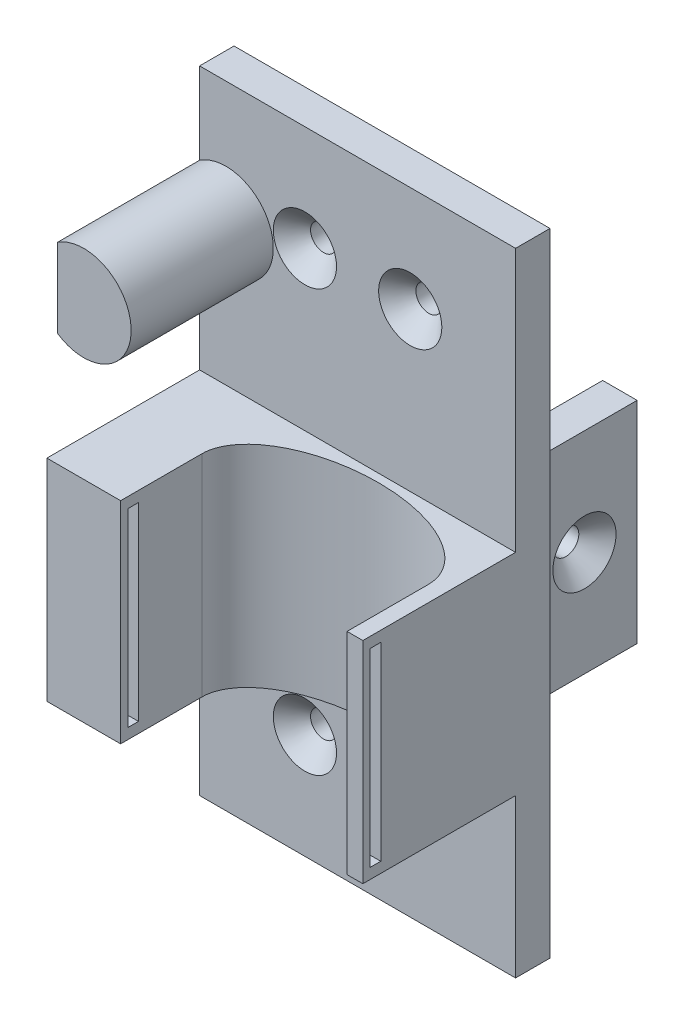
from build123d import *

# Parameters (mm, degrees)
BOSS_EXTRUDE1_DEPTH                             = 6.54
BOSS_EXTRUDE4_DEPTH                             = 27.000000000000004
CSK_FOR_M3_FLAT_HEAD_MACHINE_SCREW2_D           = 4.93
CSK_FOR_M3_FLAT_HEAD_MACHINE_SCREW2_CSINK_D     = 12
CSK_FOR_M3_FLAT_HEAD_MACHINE_SCREW2_CSINK_ANGLE = 90
BOSS_EXTRUDE5_DEPTH                             = 20
BOSS_EXTRUDE6_DEPTH                             = 28.999999999999996
CUT_EXTRUDE1_REACH                              = 86.042
SKETCH18_RX                                     = 21.5
SKETCH18_RY                                     = 11.999999999999996
CUT_EXTRUDE2_REACH                              = 89.09
CUT_EXTRUDE3_DEPTH                              = 8.999999999999996
CUT_EXTRUDE4_DEPTH                              = 8.999999999999996
CSK_FOR_M3_FLAT_HEAD_MACHINE_SCREW4_D           = 4.93
CSK_FOR_M3_FLAT_HEAD_MACHINE_SCREW4_DEPTH       = 6.54
CSK_FOR_M3_FLAT_HEAD_MACHINE_SCREW4_CSINK_D     = 12
CSK_FOR_M3_FLAT_HEAD_MACHINE_SCREW4_CSINK_ANGLE = 90
CSK_FOR_M3_FLAT_HEAD_MACHINE_SCREW5_D           = 4.93
CSK_FOR_M3_FLAT_HEAD_MACHINE_SCREW5_CSINK_D     = 12
CSK_FOR_M3_FLAT_HEAD_MACHINE_SCREW5_CSINK_ANGLE = 90


with BuildPart() as part:
    # Sketch1 → Boss-Extrude1 (new body)
    with BuildSketch(Plane.XY):
        Polygon((-30.000000000000004, 59.99999999999999), (29.999999999999996, 59.99999999999999), (30.00000000000001, -60.00000000000001), (-29.99999999999999, -60.00000000000001), align=None)
    extrude(amount=BOSS_EXTRUDE1_DEPTH)

    # Sketch7 → Boss-Extrude4 (add)
    with BuildSketch(Plane.XY.offset(6.54)):
        with BuildLine():
            Line((-30.000000000000004, 44.48331477354787), (-30.000000000000004, 29.516685226452115))
            ThreePointArc((-30.000000000000004, 29.516685226452115), (-15.999999999999986, 36.99999999999999), (-30.000000000000004, 44.48331477354787))
        make_face()
    extrude(amount=BOSS_EXTRUDE4_DEPTH)

    # CSK for M3 Flat Head Machine Screw2 (through all)
    with Locations(Plane(origin=(-10, -40, 6.54), x_dir=(1, 0, 0), z_dir=(0, 0, 1))):
        with Locations((0, 0), (20, 0), (0, 80), (20, 80)):
            CounterSinkHole(CSK_FOR_M3_FLAT_HEAD_MACHINE_SCREW2_D / 2, CSK_FOR_M3_FLAT_HEAD_MACHINE_SCREW2_CSINK_D / 2, counter_sink_angle=CSK_FOR_M3_FLAT_HEAD_MACHINE_SCREW2_CSINK_ANGLE)

    # Sketch10 → Boss-Extrude5 (add)
    with BuildSketch(Plane(origin=(0, 0, 0), x_dir=(-1, 0, 0), z_dir=(0, 0, -1))):
        Polygon((20, 20), (26.540000000000003, 20), (26.540000000000006, -20.000000000000007), (20, -20.000000000000007), align=None)
        Polygon((-20, -20), (-20, 19.999999999999993), (-26.540000000000003, 19.999999999999993), (-26.54, -20), align=None)
    extrude(amount=BOSS_EXTRUDE5_DEPTH)

    # Sketch17 → Boss-Extrude6 (add)
    with BuildSketch(Plane.XY.offset(6.54)):
        Polygon((-30, 9.999999999999995), (30.000000000000014, 9.999999999999995), (30.00000000000001, -30.000000000000007), (-29.999999999999996, -30.000000000000007), align=None)
    extrude(amount=BOSS_EXTRUDE6_DEPTH)

    # Sketch18 → Cut-Extrude1 (cut, up to next)
    with BuildSketch(Plane(origin=(0, 9.999999999999995, 0), x_dir=(1, 0, 0), z_dir=(0, 1, 0)), mode=Mode.PRIVATE) as cut_extrude1_sk1:
        with Locations((5.500000000000008, -20.091951128620167)):
            Ellipse(SKETCH18_RX, SKETCH18_RY)
    cut_extrude1_tool1 = extrude(cut_extrude1_sk1.sketch, amount=-CUT_EXTRUDE1_REACH, mode=Mode.PRIVATE) & part.part
    add(cut_extrude1_tool1.solids().sort_by_distance((5.5, 10, 20.091951))[0], mode=Mode.SUBTRACT)

    # Sketch21 → Cut-Extrude2 (cut, up to next)
    with BuildSketch(Plane.XY.offset(35.53999999999999), mode=Mode.PRIVATE) as cut_extrude2_sk1:
        Polygon((-15.99999999999999, 9.999999999999995), (27.00000000000001, 9.999999999999995), (27.00000000000002, -30.000000000000007), (-15.999999999999986, -30.000000000000007), align=None)
    cut_extrude2_tool1 = extrude(cut_extrude2_sk1.sketch, amount=-CUT_EXTRUDE2_REACH, mode=Mode.PRIVATE) & part.part
    add(cut_extrude2_tool1.solids().sort_by_distance((5.5, -10, 35.54))[0], mode=Mode.SUBTRACT)

    # Sketch23 → Cut-Extrude3 (cut)
    with BuildSketch(Plane(origin=(-15.99999999999999, -1.39e-15, 0), x_dir=(0, 0, -1), z_dir=(1, 9e-17, 0))):
        Polygon((-34.139999999999986, 7.9999999999999964), (-32.13999999999999, 7.9999999999999964), (-32.139999999999986, -28.000000000000007), (-34.139999999999986, -28), align=None)
    extrude(amount=-CUT_EXTRUDE3_DEPTH, mode=Mode.SUBTRACT)

    # Sketch24 → Cut-Extrude4 (cut)
    with BuildSketch(Plane.ZY.offset(-27.000000000000014)):
        Polygon((32.13999999999999, 7.9999999999999885), (34.14, 7.9999999999999885), (34.14, -28.00000000000001), (32.14, -28.00000000000001), align=None)
    extrude(amount=-CUT_EXTRUDE4_DEPTH, mode=Mode.SUBTRACT)

    # CSK for M3 Flat Head Machine Screw4
    with Locations(Plane(origin=(-26.54, 0, -10), x_dir=(0, -1, 0), z_dir=(-1, 0, 0))):
        with Locations((0, 0)):
            CounterSinkHole(CSK_FOR_M3_FLAT_HEAD_MACHINE_SCREW4_D / 2, CSK_FOR_M3_FLAT_HEAD_MACHINE_SCREW4_CSINK_D / 2, depth=CSK_FOR_M3_FLAT_HEAD_MACHINE_SCREW4_DEPTH, counter_sink_angle=CSK_FOR_M3_FLAT_HEAD_MACHINE_SCREW4_CSINK_ANGLE)

    # CSK for M3 Flat Head Machine Screw5 (through all)
    with Locations(Plane(origin=(26.54, 0, -10), x_dir=(0, 1, 0), z_dir=(1, 0, 0))):
        with Locations((0, 0)):
            CounterSinkHole(CSK_FOR_M3_FLAT_HEAD_MACHINE_SCREW5_D / 2, CSK_FOR_M3_FLAT_HEAD_MACHINE_SCREW5_CSINK_D / 2, counter_sink_angle=CSK_FOR_M3_FLAT_HEAD_MACHINE_SCREW5_CSINK_ANGLE)


solid = part.part
